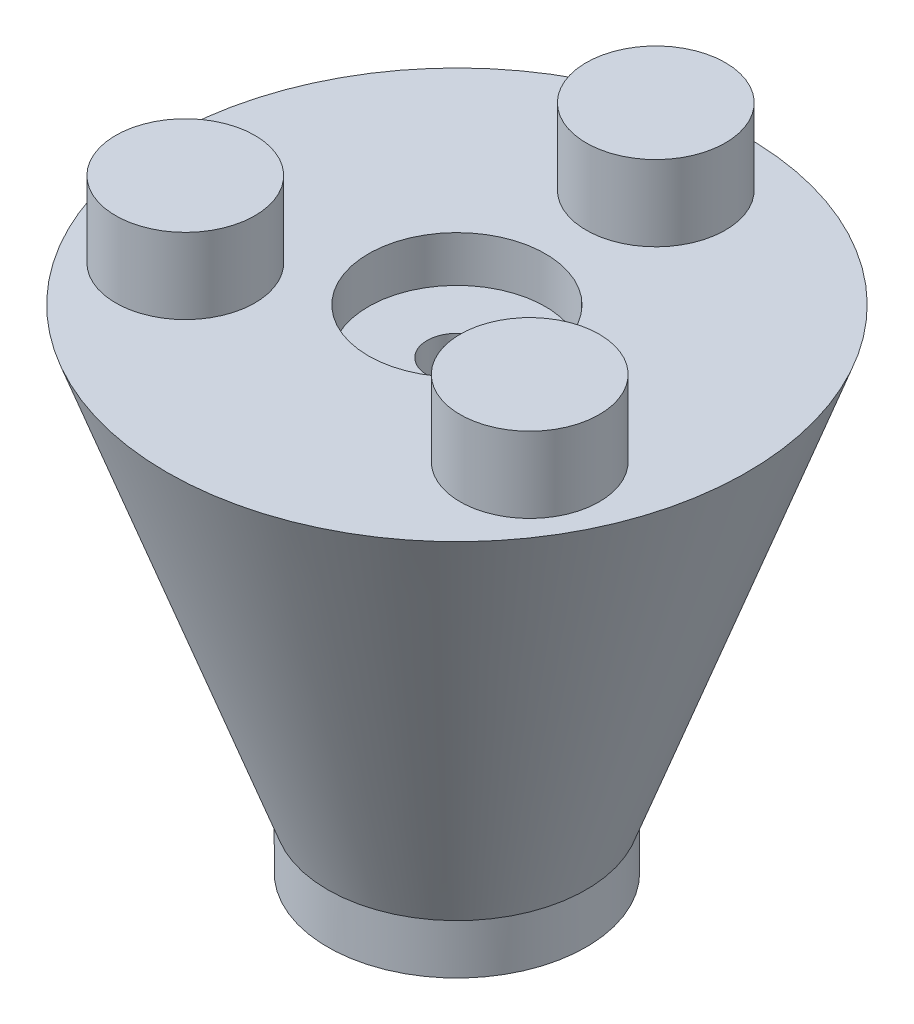
from build123d import *

# Parameters (mm, degrees)
SKETCH1_R                       = 6.5
ANGLEBODY_DEPTH                 = 22.225
ANGLEBODY_DRAFT                 = -20
SKETCH2_R                       = 3.3
SKETCH2_R_2                     = 1.5
CENTERHOLE_DEPTH                = 31.325606053
F_40TPEGS_DEPTH                 = 3.8
SKETCH3_R                       = 6.5
SKETCH3_R_2                     = 3.300000004
F_20TINTERFACE_DEPTH            = 2.5
F_40TGEARHUBINTERFACEPROFILE_R  = 4.45
F_40TGEARHUBINTERFACEHOLE_DEPTH = 15
BOSS_EXTRUDE1_START             = -2.3
SKETCH5_R                       = 4.45
SKETCH5_R_2                     = 1.5
BOSS_EXTRUDE1_DEPTH             = 15
SKETCH6_R                       = 3.3
SKETCH6_R_2                     = 1.5
BOSS_EXTRUDE2_DEPTH             = 7.425


with BuildPart() as part:
    # Sketch1 → AngleBody (with draft: the straight prism first)
    with BuildSketch(Plane(origin=(0, 0, 0), x_dir=(1, 0, 0), z_dir=(0, 1, 0))):
        Circle(SKETCH1_R)
    extrude(amount=ANGLEBODY_DEPTH)
    # AngleBody: the draft: its side faces are tilted about the plane it starts from
    anglebody_sides = [part.faces().sort_by_distance(p)[0] for p in [
        (-6.5, 11.1125, 0),
    ]]
    draft(anglebody_sides, Plane(origin=(0, 0, 0), x_dir=(1, 0, 0), z_dir=(0, 1, 0)), ANGLEBODY_DRAFT)

    # Sketch2 → CenterHole (cut, through all)
    # profile 1 of 2: a face of its own
    with BuildSketch(Plane(origin=(0, 22.225, 0), x_dir=(1, 0, 0), z_dir=(0, 1, 0))):
        with Locations(Location((0, 0, 0), (0, 0, 270))):
            Circle(SKETCH2_R)
    # profile 2 of 2: a face of its own
    with BuildSketch(Plane(origin=(0, 22.225, 0), x_dir=(1, 0, 0), z_dir=(0, 1, 0))):
        with Locations(Location((0, 0, 0), (0, 0, 270))):
            Circle(SKETCH2_R)
        Circle(SKETCH2_R_2, mode=Mode.SUBTRACT)
    extrude(amount=-CENTERHOLE_DEPTH, mode=Mode.SUBTRACT)

    # Sketch2_3 → 40tPegs (add)
    with BuildSketch(Plane(origin=(0, 22.225, 0), x_dir=(1, 0, 0), z_dir=(0, 1, 0))):
        with BuildLine():
            ThreePointArc((3.500000004, 10), (-1.750000002, 13.031088917), (-1.750000002, 6.968911083))
            Line((-1.750000002, 6.968911083), (0, 10))
            Line((0, 10), (1.750000002, 6.968911083))
            ThreePointArc((1.750000002, 6.968911083), (3.031088917, 8.249999998), (3.500000004, 10))
        make_face()
        with BuildLine():
            Line((0, 10), (-1.750000002, 6.968911083))
            ThreePointArc((-1.750000002, 6.968911083), (0, 6.499999996), (1.750000002, 6.968911083))
            Line((1.750000002, 6.968911083), (0, 10))
        make_face()
        with BuildLine():
            ThreePointArc((3.500000004, 10), (-1.750000002, 13.031088917), (-1.750000002, 6.968911083))
            Line((-1.750000002, 6.968911083), (0, 10))
            Line((0, 10), (1.750000002, 6.968911083))
            ThreePointArc((1.750000002, 6.968911083), (3.031088917, 8.249999998), (3.500000004, 10))
        make_face()
        with BuildLine():
            Line((0, 10), (-1.750000002, 6.968911083))
            ThreePointArc((-1.750000002, 6.968911083), (0, 6.499999996), (1.750000002, 6.968911083))
            Line((1.750000002, 6.968911083), (0, 10))
        make_face()
        with BuildLine():
            Line((-6.910254038, -1.968911087), (-8.660254038, -5))
            Line((-8.660254038, -5), (-5.160254038, -5))
            ThreePointArc((-5.160254038, -5), (-5.629165125, -3.25), (-6.910254038, -1.968911087))
        make_face()
        with BuildLine():
            Line((-5.160254038, -5), (-8.660254038, -5))
            Line((-8.660254038, -5), (-6.910254038, -1.968911087))
            ThreePointArc((-6.910254038, -1.968911087), (-11.691342951, -6.75), (-5.160254038, -5))
        make_face()
        with BuildLine():
            Line((-6.910254038, -1.968911087), (-8.660254038, -5))
            Line((-8.660254038, -5), (-5.160254038, -5))
            ThreePointArc((-5.160254038, -5), (-5.629165125, -3.25), (-6.910254038, -1.968911087))
        make_face()
        with BuildLine():
            Line((-5.160254038, -5), (-8.660254038, -5))
            Line((-8.660254038, -5), (-6.910254038, -1.968911087))
            ThreePointArc((-6.910254038, -1.968911087), (-11.691342951, -6.75), (-5.160254038, -5))
        make_face()
        with BuildLine():
            ThreePointArc((6.910254038, -1.968911087), (5.629165125, -3.25), (5.160254038, -5))
            Line((5.160254038, -5), (8.660254038, -5))
            Line((8.660254038, -5), (6.910254038, -1.968911087))
        make_face()
        with BuildLine():
            Line((8.660254038, -5), (5.160254038, -5))
            ThreePointArc((5.160254038, -5), (8.660254038, -8.5), (12.160254038, -5))
            ThreePointArc((12.160254038, -5), (10.410254038, -1.968911087), (6.910254038, -1.968911087))
            Line((6.910254038, -1.968911087), (8.660254038, -5))
        make_face()
        with BuildLine():
            ThreePointArc((6.910254038, -1.968911087), (5.629165125, -3.25), (5.160254038, -5))
            Line((5.160254038, -5), (8.660254038, -5))
            Line((8.660254038, -5), (6.910254038, -1.968911087))
        make_face()
        with BuildLine():
            Line((8.660254038, -5), (5.160254038, -5))
            ThreePointArc((5.160254038, -5), (8.660254038, -8.5), (12.160254038, -5))
            ThreePointArc((12.160254038, -5), (10.410254038, -1.968911087), (6.910254038, -1.968911087))
            Line((6.910254038, -1.968911087), (8.660254038, -5))
        make_face()
    extrude(amount=F_40TPEGS_DEPTH)

    # Sketch3 → 20tInterface (add)
    with BuildSketch(Plane.XZ):
        with Locations(Location((0, 0, 0), (0, 0, 270))):
            Circle(SKETCH3_R)
        with Locations(Location((0, 0, 0), (0, 0, 90))):
            Circle(SKETCH3_R_2, mode=Mode.SUBTRACT)
    extrude(amount=F_20TINTERFACE_DEPTH)

    # 40tGearHubInterfaceProfile → 40tGearHubInterfaceHole (cut)
    with BuildSketch(Plane(origin=(0, 22.225, 0), x_dir=(1, 0, 0), z_dir=(0, 1, 0))):
        with Locations(Location((0, 0, 0), (0, 0, 270))):
            Circle(F_40TGEARHUBINTERFACEPROFILE_R)
    extrude(amount=-F_40TGEARHUBINTERFACEHOLE_DEPTH, mode=Mode.SUBTRACT)

    # Sketch5 → Boss-Extrude1 (add)
    with BuildSketch(Plane(origin=(0, 22.225, 0), x_dir=(1, 0, 0), z_dir=(0, 1, 0)).offset(BOSS_EXTRUDE1_START)):
        with Locations(Location((0, 0, 0), (0, 0, 270))):
            Circle(SKETCH5_R)
        with Locations(Location((0, 0, 0), (0, 0, 270))):
            Circle(SKETCH5_R_2, mode=Mode.SUBTRACT)
    extrude(amount=-BOSS_EXTRUDE1_DEPTH)


with BuildPart() as body_2:
    # Sketch6 → Boss-Extrude2 (new body)
    with BuildSketch(Plane.XZ.offset(-4.925)):
        with Locations(Location((0, 0, 0), (0, 0, 270))):
            Circle(SKETCH6_R)
        with Locations(Location((0, 0, 0), (0, 0, 270))):
            Circle(SKETCH6_R_2, mode=Mode.SUBTRACT)
    extrude(amount=BOSS_EXTRUDE2_DEPTH)

    # loft up to a face of the part (cut_loft2)
    loft([Face(Wire([body_2.edges().sort_by_distance((2.40559647, -2.5, 2.25900545))[0]])), Face(Wire([body_2.edges().sort_by_distance((1.093452941, 4.925, 1.026820659))[0]]))], mode=Mode.SUBTRACT)


solid = Compound([part.part, body_2.part])
